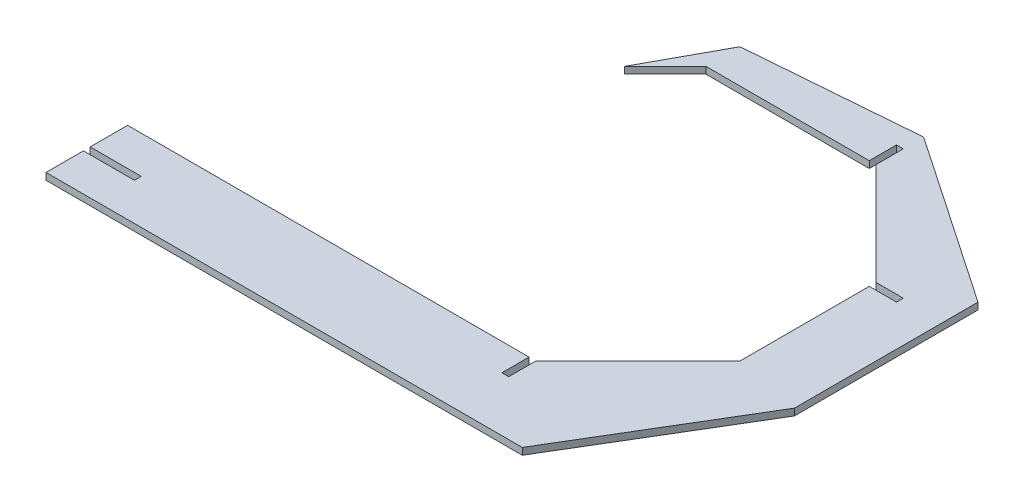
from build123d import *

# Parameters (mm, degrees)
BOSS_EXTRUDE1_DEPTH = 2.54
SKETCH2_W           = 19.05
SKETCH2_H           = 2.54
SKETCH2_W_2         = 2.54
SKETCH2_H_2         = 10.16
SKETCH2_W_3         = 10.16
CUT_EXTRUDE1_DEPTH  = 3.54


with BuildPart() as part:
    # Sketch1 → Boss-Extrude1 (new body)
    with BuildSketch(Plane(origin=(0, 0, 0), x_dir=(1, 0, 0), z_dir=(0, 1, 0))):
        Polygon((0, 0), (0, -30.48), (177.8, -30.48), (215.9, 33.02), (215.9, 101.555269233), (152.4, 144.78), (88.9, 139.7), (73.66, 111.76), (88.9, 127), (152.4, 127), (190.5, 88.9), (190.5, 38.1), (152.4, 0), align=None)
    extrude(amount=BOSS_EXTRUDE1_DEPTH)

    # Sketch2 → Cut-Extrude1 (cut, through all)
    with BuildSketch(Plane(origin=(0, 2.54, 0), x_dir=(1, 0, 0), z_dir=(0, 1, 0))):
        with Locations((9.525, -15.24)):
            Rectangle(SKETCH2_W, SKETCH2_H)
        with Locations((151.13, -5.08)):
            Rectangle(SKETCH2_W_2, SKETCH2_H_2)
        with Locations((195.58, 87.63)):
            Rectangle(SKETCH2_W_3, SKETCH2_H)
        with Locations((151.13, 132.08)):
            Rectangle(SKETCH2_W_2, SKETCH2_H_2)
    extrude(amount=-CUT_EXTRUDE1_DEPTH, mode=Mode.SUBTRACT)


solid = part.part
